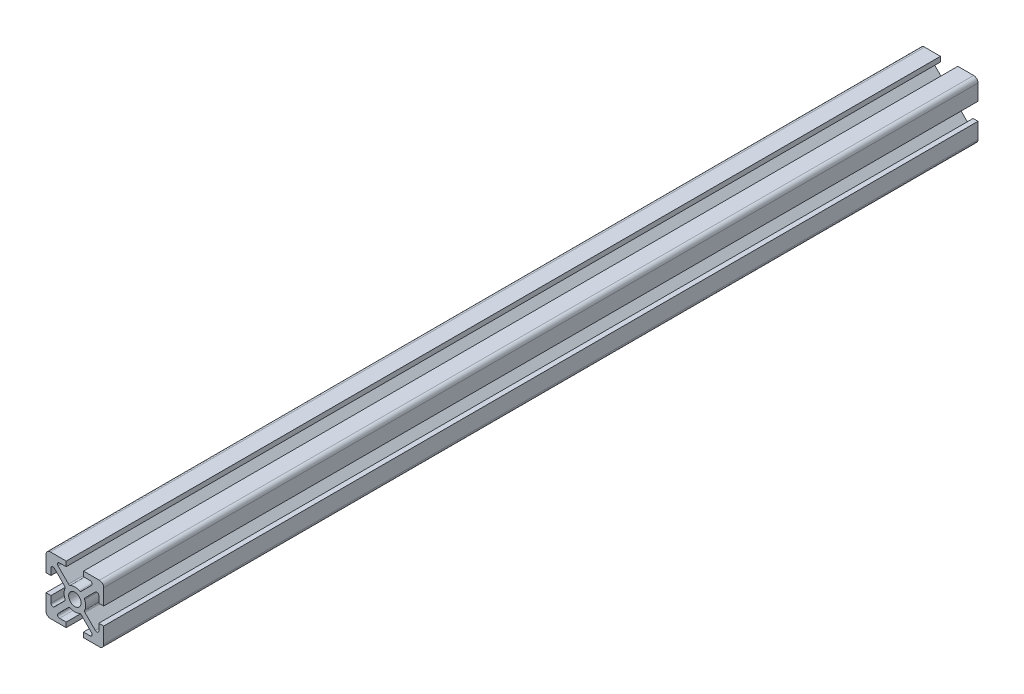
from build123d import *

# Parameters (mm, degrees)
ESQUISSE1_R        = 2.15
BOSS_EXTRU_1_DEPTH = 303


with BuildPart() as part:
    # Esquisse1 → Boss.-Extru.1 (new body)
    with BuildSketch(Plane.XY):
        with BuildLine():
            Line((-3, 10), (-8.5, 10))
            ThreePointArc((-8.5, 10), (-9.560660172, 9.560660172), (-10, 8.5))
            Line((-10, 8.5), (-10, 3))
            Line((-10, 3), (-8.300000103, 3))
            Line((-8.300000103, 3), (-8.300000103, 5.299391013))
            ThreePointArc((-8.300000103, 5.299391013), (-7.867878523, 5.946106661), (-7.105025403, 5.794365741))
            Line((-7.105025403, 5.794365741), (-3.486125569, 2.175465907))
            ThreePointArc((-3.486125569, 2.175465907), (-3.346986783, 1.907085393), (-3.38795202, 1.607569866))
            ThreePointArc((-3.38795202, 1.607569866), (-3.749999968, 1.37e-07), (-3.387952137, -1.607569618))
            ThreePointArc((-3.387952137, -1.607569618), (-3.346986918, -1.907085124), (-3.486125693, -2.175465617))
            Line((-3.486125693, -2.175465617), (-7.10502539, -5.794365497))
            ThreePointArc((-7.10502539, -5.794365497), (-7.867878514, -5.946106433), (-8.300000103, -5.299390782))
            Line((-8.300000103, -5.299390782), (-8.300000103, -3))
            Line((-8.300000103, -3), (-10, -3))
            Line((-10, -3), (-10, -8.5))
            ThreePointArc((-10, -8.5), (-9.560660172, -9.560660172), (-8.5, -10))
            Line((-8.5, -10), (-3, -10))
            Line((-3, -10), (-3, -8.29999992))
            Line((-3, -8.29999992), (-5.299390173, -8.29999992))
            ThreePointArc((-5.299390173, -8.29999992), (-5.94610582, -7.867878342), (-5.794364905, -7.105025224))
            Line((-5.794364905, -7.105025224), (-2.175465502, -3.486125765))
            ThreePointArc((-2.175465502, -3.486125765), (-1.907085014, -3.346986981), (-1.607569506, -3.38795219))
            ThreePointArc((-1.607569506, -3.38795219), (1.99e-07, -3.749999968), (1.607569866, -3.38795202))
            ThreePointArc((1.607569866, -3.38795202), (1.907085393, -3.346986783), (2.175465907, -3.486125569))
            Line((2.175465907, -3.486125569), (5.794365558, -7.10502522))
            ThreePointArc((5.794365558, -7.10502522), (5.946106478, -7.86787834), (5.29939083, -8.29999992))
            Line((5.29939083, -8.29999992), (3, -8.29999992))
            Line((3, -8.29999992), (3, -10))
            Line((3, -10), (8.499999896, -10))
            ThreePointArc((8.499999896, -10), (9.560660068, -9.560660172), (9.999999896, -8.5))
            Line((9.999999896, -8.5), (9.999999896, -3))
            Line((9.999999896, -3), (8.300000103, -3))
            Line((8.300000103, -3), (8.300000103, -5.299391569))
            ThreePointArc((8.300000103, -5.299391569), (7.867878509, -5.946107222), (7.105025381, -5.794366275))
            Line((7.105025381, -5.794366275), (3.486125475, -2.175466057))
            ThreePointArc((3.486125475, -2.175466057), (3.346986701, -1.907085538), (3.38795195, -1.607570012))
            ThreePointArc((3.38795195, -1.607570012), (3.658368452, -0.823917488), (3.749999968, 0))
            ThreePointArc((3.749999968, 0), (3.658368507, 0.823917244), (3.387952165, 1.607569559))
            ThreePointArc((3.387952165, 1.607569559), (3.346986951, 1.907085066), (3.486125731, 2.175465556))
            Line((3.486125731, 2.175465556), (7.105025399, 5.79436528))
            ThreePointArc((7.105025399, 5.79436528), (7.86787852, 5.946106205), (8.300000103, 5.299390557))
            Line((8.300000103, 5.299390557), (8.300000103, 3))
            Line((8.300000103, 3), (9.999999896, 3))
            Line((9.999999896, 3), (9.999999896, 8.5))
            ThreePointArc((9.999999896, 8.5), (9.560660068, 9.560660172), (8.499999896, 10))
            Line((8.499999896, 10), (3.499999896, 10))
            Line((3.499999896, 10), (3, 10))
            Line((3, 10), (3, 8.29999992))
            Line((3, 8.29999992), (5.299389948, 8.29999992))
            ThreePointArc((5.299389948, 8.29999992), (5.946105592, 7.867878348), (5.794364688, 7.105025232))
            Line((5.794364688, 7.105025232), (2.175465441, 3.486125803))
            ThreePointArc((2.175465441, 3.486125803), (1.907084956, 3.346987014), (1.607569447, 3.387952218))
            ThreePointArc((1.607569447, 3.387952218), (-1.51e-07, 3.749999968), (-1.60756972, 3.387952089))
            ThreePointArc((-1.60756972, 3.387952089), (-1.907085249, 3.346986865), (-2.175465757, 3.486125663))
            Line((-2.175465757, 3.486125663), (-5.794365024, 7.105025241))
            ThreePointArc((-5.794365024, 7.105025241), (-5.946105917, 7.867878353), (-5.299390275, 8.29999992))
            Line((-5.299390275, 8.29999992), (-3, 8.29999992))
            Line((-3, 8.29999992), (-3, 10))
        make_face()
        Circle(ESQUISSE1_R, mode=Mode.SUBTRACT)
    extrude(amount=BOSS_EXTRU_1_DEPTH)


solid = part.part
